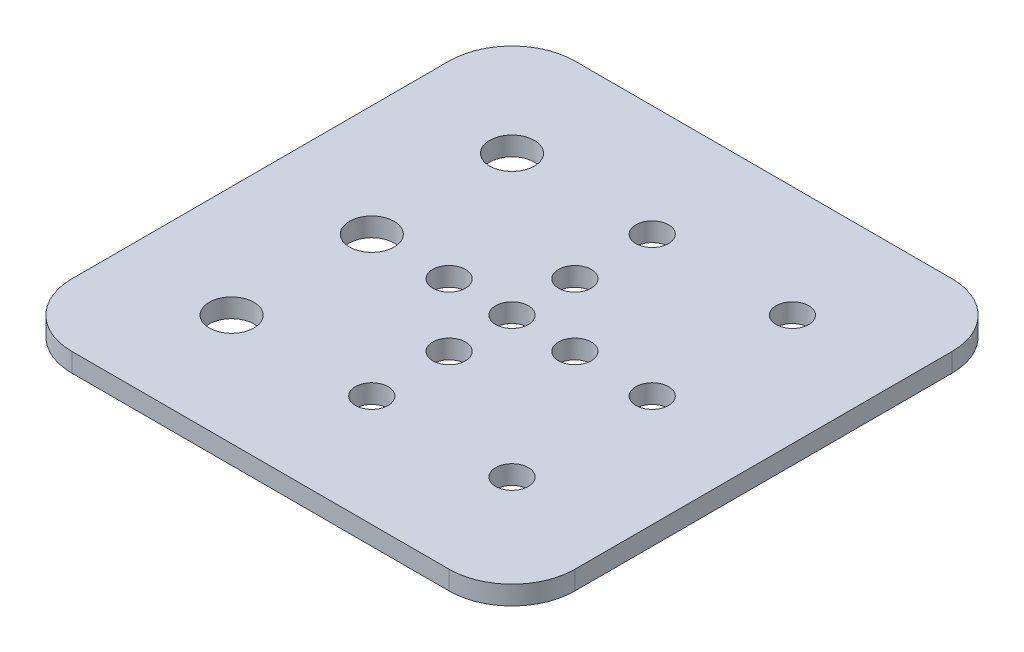
from build123d import *

# Parameters (mm, degrees)
SKETCH1_R           = 2.6
SKETCH1_R_2         = 3.55
BOSS_EXTRUDE1_DEPTH = 3


with BuildPart() as part:
    # Sketch1 → Boss-Extrude1 (new body)
    with BuildSketch(Plane(origin=(0, 0, 0), x_dir=(1, 0, 0), z_dir=(0, 1, 0))):
        with BuildLine():
            Line((30, -40), (-30, -40))
            ThreePointArc((-30, -40), (-37.071067812, -37.071067812), (-40, -30))
            Line((-40, -30), (-40, 30))
            ThreePointArc((-40, 30), (-37.071067812, 37.071067812), (-30, 40))
            Line((-30, 40), (30, 40))
            ThreePointArc((30, 40), (37.071067812, 37.071067812), (40, 30))
            Line((40, 30), (40, -30))
            ThreePointArc((40, -30), (37.071067812, -37.071067812), (30, -40))
        make_face()
        Circle(SKETCH1_R, mode=Mode.SUBTRACT)
        with Locations((0, -10)):
            Circle(SKETCH1_R, mode=Mode.SUBTRACT)
        with Locations((-10, 0)):
            Circle(SKETCH1_R, mode=Mode.SUBTRACT)
        with Locations((10, 0)):
            Circle(SKETCH1_R, mode=Mode.SUBTRACT)
        with Locations((0, 10)):
            Circle(SKETCH1_R, mode=Mode.SUBTRACT)
        with Locations((-22.3, 22.3)):
            Circle(SKETCH1_R_2, mode=Mode.SUBTRACT)
        with Locations((-22.3, 0)):
            Circle(SKETCH1_R_2, mode=Mode.SUBTRACT)
        with Locations((-22.3, -22.3)):
            Circle(SKETCH1_R_2, mode=Mode.SUBTRACT)
        with Locations((0, 22.3)):
            Circle(SKETCH1_R, mode=Mode.SUBTRACT)
        with Locations((0, -22.3)):
            Circle(SKETCH1_R, mode=Mode.SUBTRACT)
        with Locations((22.3, 22.3)):
            Circle(SKETCH1_R, mode=Mode.SUBTRACT)
        with Locations((22.3, 0)):
            Circle(SKETCH1_R, mode=Mode.SUBTRACT)
        with Locations((22.3, -22.3)):
            Circle(SKETCH1_R, mode=Mode.SUBTRACT)
    extrude(amount=BOSS_EXTRUDE1_DEPTH)


solid = part.part
